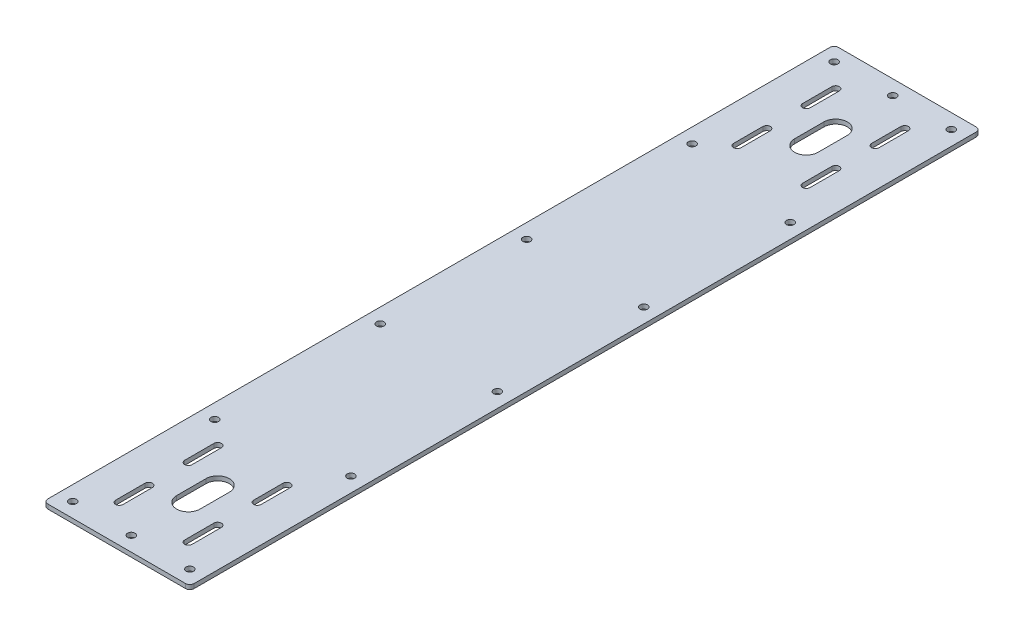
from build123d import *

# Parameters (mm, degrees)
SKETCH1_R           = 2.55
BOSS_EXTRUDE1_DEPTH = 3


with BuildPart() as part:
    # Sketch1 → Boss-Extrude1 (new body)
    with BuildSketch(Plane(origin=(0, 0, 0), x_dir=(1, 0, 0), z_dir=(0, 1, 0))):
        with BuildLine():
            Line((-47, 290), (47, 290))
            ThreePointArc((47, 290), (49.121320344, 289.121320344), (50, 287))
            Line((50, 287), (50, -247))
            ThreePointArc((50, -247), (49.121320344, -249.121320344), (47, -250))
            Line((47, -250), (-47, -250))
            ThreePointArc((-47, -250), (-49.121320344, -249.121320344), (-50, -247))
            Line((-50, -247), (-50, 287))
            ThreePointArc((-50, 287), (-49.121320344, 289.121320344), (-47, 290))
        make_face()
        with Locations((-40, 280)):
            Circle(SKETCH1_R, mode=Mode.SUBTRACT)
        with Locations((0, 280)):
            Circle(SKETCH1_R, mode=Mode.SUBTRACT)
        with Locations((40, 280)):
            Circle(SKETCH1_R, mode=Mode.SUBTRACT)
        with Locations((-40, -240)):
            Circle(SKETCH1_R, mode=Mode.SUBTRACT)
        with Locations((0, -240)):
            Circle(SKETCH1_R, mode=Mode.SUBTRACT)
        with Locations((40, -240)):
            Circle(SKETCH1_R, mode=Mode.SUBTRACT)
        with Locations((-40, 183)):
            Circle(SKETCH1_R, mode=Mode.SUBTRACT)
        with Locations((-40, 70)):
            Circle(SKETCH1_R, mode=Mode.SUBTRACT)
        with Locations((-40, -30)):
            Circle(SKETCH1_R, mode=Mode.SUBTRACT)
        with Locations((-40, -143)):
            Circle(SKETCH1_R, mode=Mode.SUBTRACT)
        with Locations((40, 170)):
            Circle(SKETCH1_R, mode=Mode.SUBTRACT)
        with Locations((40, 70)):
            Circle(SKETCH1_R, mode=Mode.SUBTRACT)
        with Locations((40, -30)):
            Circle(SKETCH1_R, mode=Mode.SUBTRACT)
        with Locations((40, -130)):
            Circle(SKETCH1_R, mode=Mode.SUBTRACT)
        with BuildLine():
            Line((-26.12, 244.57), (-26.12, 264.57))
            ThreePointArc((-26.12, 264.57), (-23.57, 267.12), (-21.02, 264.57))
            Line((-21.02, 264.57), (-21.02, 244.57))
            ThreePointArc((-21.02, 244.57), (-23.57, 242.02), (-26.12, 244.57))
        make_face(mode=Mode.SUBTRACT)
        with BuildLine():
            Line((26.12, 264.57), (26.12, 244.57))
            ThreePointArc((26.12, 244.57), (23.57, 242.02), (21.02, 244.57))
            Line((21.02, 244.57), (21.02, 264.57))
            ThreePointArc((21.02, 264.57), (23.57, 267.12), (26.12, 264.57))
        make_face(mode=Mode.SUBTRACT)
        with BuildLine():
            Line((26.12, 217.43), (26.12, 197.43))
            ThreePointArc((26.12, 197.43), (23.57, 194.88), (21.02, 197.43))
            Line((21.02, 197.43), (21.02, 217.43))
            ThreePointArc((21.02, 217.43), (23.57, 219.98), (26.12, 217.43))
        make_face(mode=Mode.SUBTRACT)
        with BuildLine():
            Line((-21.02, 217.43), (-21.02, 197.43))
            ThreePointArc((-21.02, 197.43), (-23.57, 194.88), (-26.12, 197.43))
            Line((-26.12, 197.43), (-26.12, 217.43))
            ThreePointArc((-26.12, 217.43), (-23.57, 219.98), (-21.02, 217.43))
        make_face(mode=Mode.SUBTRACT)
        with BuildLine():
            Line((-26.12, -177.43), (-26.12, -157.43))
            ThreePointArc((-26.12, -157.43), (-23.57, -154.88), (-21.02, -157.43))
            Line((-21.02, -157.43), (-21.02, -177.43))
            ThreePointArc((-21.02, -177.43), (-23.57, -179.98), (-26.12, -177.43))
        make_face(mode=Mode.SUBTRACT)
        with BuildLine():
            Line((26.12, -157.43), (26.12, -177.43))
            ThreePointArc((26.12, -177.43), (23.57, -179.98), (21.02, -177.43))
            Line((21.02, -177.43), (21.02, -157.43))
            ThreePointArc((21.02, -157.43), (23.57, -154.88), (26.12, -157.43))
        make_face(mode=Mode.SUBTRACT)
        with BuildLine():
            Line((26.12, -204.57), (26.12, -224.57))
            ThreePointArc((26.12, -224.57), (23.57, -227.12), (21.02, -224.57))
            Line((21.02, -224.57), (21.02, -204.57))
            ThreePointArc((21.02, -204.57), (23.57, -202.02), (26.12, -204.57))
        make_face(mode=Mode.SUBTRACT)
        with BuildLine():
            Line((-21.02, -204.57), (-21.02, -224.57))
            ThreePointArc((-21.02, -224.57), (-23.57, -227.12), (-26.12, -224.57))
            Line((-26.12, -224.57), (-26.12, -204.57))
            ThreePointArc((-26.12, -204.57), (-23.57, -202.02), (-21.02, -204.57))
        make_face(mode=Mode.SUBTRACT)
        with BuildLine():
            Line((8, 241), (8, 221))
            ThreePointArc((8, 221), (0, 213), (-8, 221))
            Line((-8, 221), (-8, 241))
            ThreePointArc((-8, 241), (0, 249), (8, 241))
        make_face(mode=Mode.SUBTRACT)
        with BuildLine():
            Line((8, -181), (8, -201))
            ThreePointArc((8, -201), (0, -209), (-8, -201))
            Line((-8, -201), (-8, -181))
            ThreePointArc((-8, -181), (0, -173), (8, -181))
        make_face(mode=Mode.SUBTRACT)
    extrude(amount=BOSS_EXTRUDE1_DEPTH)


solid = part.part
